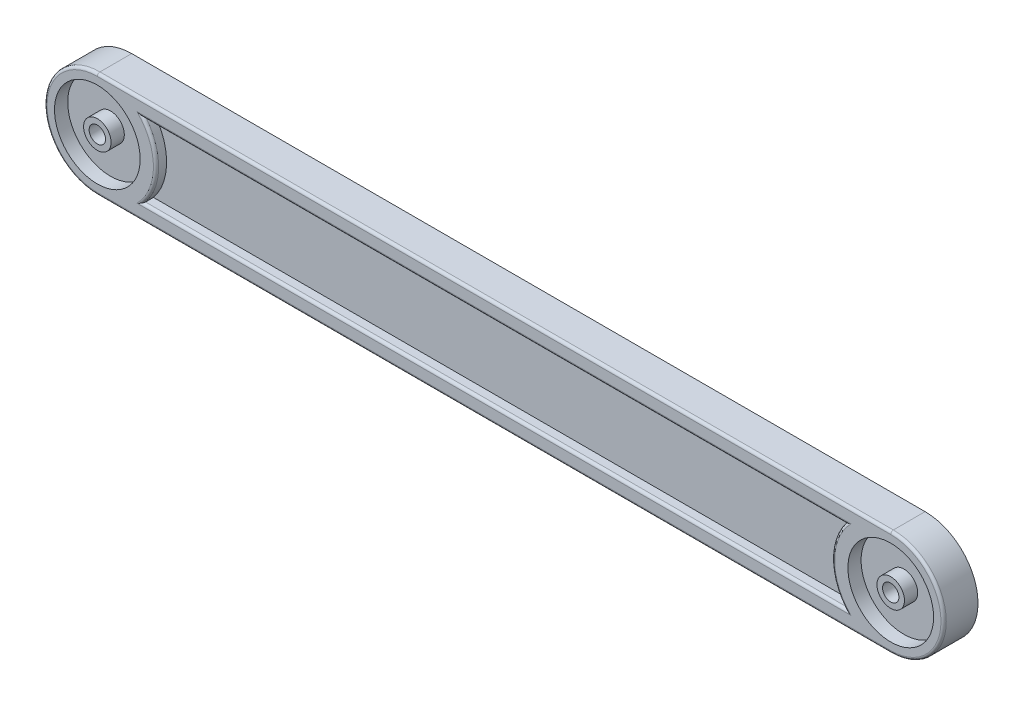
from build123d import *

# Parameters (mm, degrees)
BASE_R              = 2.6
BASE_R_2            = 8.1
BASE_R_3            = 1.55
BOSS_EXTRUDE1_DEPTH = 4
BOSS_EXTRUDE2_START = 4
BASE_3_R            = 8.1
BASE_3_R_2          = 2.6
BASE_3_R_3          = 1.55
BOSS_EXTRUDE2_DEPTH = 2.5
SKETCH2_R           = 3
CUT_EXTRUDE1_DEPTH  = 3
CUT_EXTRUDE2_DEPTH  = 2
FILLET1_R           = 0.5


with BuildPart() as part:
    # Base → Boss-Extrude1 (new body)
    with BuildSketch(Plane.XY):
        with BuildLine():
            ThreePointArc((75, 10), (85, 0), (75, -10))
            Line((75, -10), (-75, -10))
            ThreePointArc((-75, -10), (-85, 0), (-75, 10))
            Line((-75, 10), (75, 10))
        make_face()
        with Locations((75, 0)):
            Circle(BASE_R, mode=Mode.SUBTRACT)
        with Locations((-75, 0)):
            Circle(BASE_R, mode=Mode.SUBTRACT)
        with Locations((75, 0)):
            Circle(BASE_R_2)
        with Locations((75, 0)):
            Circle(BASE_R, mode=Mode.SUBTRACT)
        with Locations((75, 0)):
            Circle(BASE_R)
        with Locations((75, 0)):
            Circle(BASE_R_3, mode=Mode.SUBTRACT)
        with Locations((-75, 0)):
            Circle(BASE_R_2)
        with Locations((-75, 0)):
            Circle(BASE_R, mode=Mode.SUBTRACT)
        with Locations((-75, 0)):
            Circle(BASE_R)
        with Locations((-75, 0)):
            Circle(BASE_R_3, mode=Mode.SUBTRACT)
    extrude(amount=BOSS_EXTRUDE1_DEPTH)

    # Base_3 → Boss-Extrude2 (add)
    with BuildSketch(Plane.XY.offset(BOSS_EXTRUDE2_START)):
        with BuildLine():
            ThreePointArc((75, 10), (85, 0), (75, -10))
            Line((75, -10), (-75, -10))
            ThreePointArc((-75, -10), (-85, 0), (-75, 10))
            Line((-75, 10), (75, 10))
        make_face()
        with Locations((-75, 0)):
            Circle(BASE_3_R, mode=Mode.SUBTRACT)
        with Locations((75, 0)):
            Circle(BASE_3_R, mode=Mode.SUBTRACT)
        with Locations((75, 0)):
            Circle(BASE_3_R_2)
        with Locations((75, 0)):
            Circle(BASE_3_R_3, mode=Mode.SUBTRACT)
        with Locations((-75, 0)):
            Circle(BASE_3_R_2)
        with Locations((-75, 0)):
            Circle(BASE_3_R_3, mode=Mode.SUBTRACT)
    extrude(amount=BOSS_EXTRUDE2_DEPTH)

    # Sketch2 → Cut-Extrude1 (cut)
    with BuildSketch(Plane(origin=(0, 0, 0), x_dir=(-1, 0, 0), z_dir=(0, 0, -1))):
        with Locations((-75, 0)):
            Circle(SKETCH2_R)
        Polygon((72.125, 1.659882024), (72.125, -1.659882024), (75, -3.319764048), (77.875, -1.659882024), (77.875, 1.659882024), (75, 3.319764048), align=None)
    extrude(amount=-CUT_EXTRUDE1_DEPTH, mode=Mode.SUBTRACT)

    # Sketch3 → Cut-Extrude2 (cut)
    with BuildSketch(Plane.XY.offset(6.5)):
        with BuildLine():
            Line((66.385477378, -7), (-66.385477378, -7))
            ThreePointArc((-66.385477378, -7), (-63.9, 0), (-66.385477378, 7))
            Line((-66.385477378, 7), (66.385477378, 7))
            ThreePointArc((66.385477378, 7), (63.9, 0), (66.385477378, -7))
        make_face()
    extrude(amount=-CUT_EXTRUDE2_DEPTH, mode=Mode.SUBTRACT)

    # Fillet1
    fillet1_edges = [part.edges().sort_by_distance(p)[0] for p in [
        (85, 0, 6.5),
        (0, 10, 6.5),
        (-85, 0, 6.5),
        (0, -10, 6.5),
        (63.9, 0, 6.5),
        (0, 7, 6.5),
        (-63.9, 0, 6.5),
        (0, -7, 6.5),
    ]]
    fillet(fillet1_edges, radius=FILLET1_R)


solid = part.part
